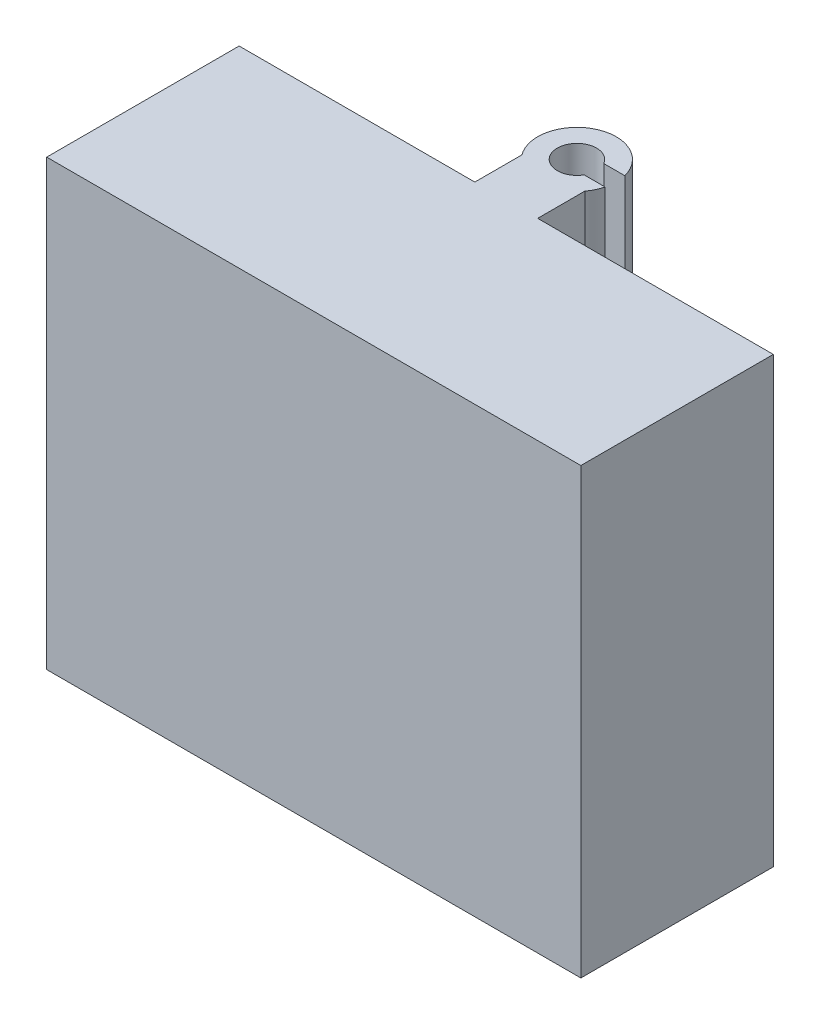
from build123d import *

# Parameters (mm, degrees)
SKETCH_1_W          = 68
SKETCH_1_H          = 56.5
EXTRUDE_1_DEPTH     = 24.5
SKETCH_4_W          = 65.1
SKETCH_4_H          = 21.5
CUT_EXTRUDE_2_DEPTH = 55
SKETCH_6_W          = 8
SKETCH_6_H          = 56.5
EXTRUDE_3_DEPTH     = 6
EXTRUDE_4_DEPTH     = 56.5
SKETCH_9_W          = 19
SKETCH_9_H          = 33
CUT_EXTRUDE_3_DEPTH = 15


with BuildPart() as part:
    # 草图1 → 凸台-拉伸1 (new body)
    with BuildSketch(Plane.XY):
        with Locations((34, -28.25)):
            Rectangle(SKETCH_1_W, SKETCH_1_H)
    extrude(amount=EXTRUDE_1_DEPTH)

    # 草图4 → 切除-拉伸2 (cut)
    with BuildSketch(Plane.XZ.offset(56.5)):
        with Locations((34, 12.25)):
            Rectangle(SKETCH_4_W, SKETCH_4_H)
    extrude(amount=-CUT_EXTRUDE_2_DEPTH, mode=Mode.SUBTRACT)

    # 草图6 → 凸台-拉伸3 (add)
    with BuildSketch(Plane(origin=(0, 0, 0), x_dir=(-1, 0, 0), z_dir=(0, 0, -1))):
        with Locations((-34, -28.25)):
            Rectangle(SKETCH_6_W, SKETCH_6_H)
    extrude(amount=EXTRUDE_3_DEPTH)

    # 草图8 → 凸台-拉伸4 (add)
    with BuildSketch(Plane(origin=(0, 0, 0), x_dir=(1, 0, 0), z_dir=(0, 1, 0))):
        with BuildLine():
            Line((34, 6), (38, 6))
            ThreePointArc((38, 6), (38.50637974, 6.833772488), (38.841229183, 7.75))
            Line((38.841229183, 7.75), (36.165055224, 7.75))
            ThreePointArc((36.165055224, 7.75), (31.500007176, 9), (36.165055224, 10.25))
            Line((36.165055224, 10.25), (38.841229183, 10.25))
            ThreePointArc((38.841229183, 10.25), (31.833772488, 13.50637974), (30, 6))
            Line((30, 6), (34, 6))
        make_face()
    extrude(amount=-EXTRUDE_4_DEPTH)

    # 草图9 → 切除-拉伸3 (cut)
    with BuildSketch(Plane(origin=(0, 0, 0), x_dir=(-1, 0, 0), z_dir=(0, 0, -1))):
        with Locations((-33.897010853, -40)):
            Rectangle(SKETCH_9_W, SKETCH_9_H)
    extrude(amount=CUT_EXTRUDE_3_DEPTH, mode=Mode.SUBTRACT)


solid = part.part
